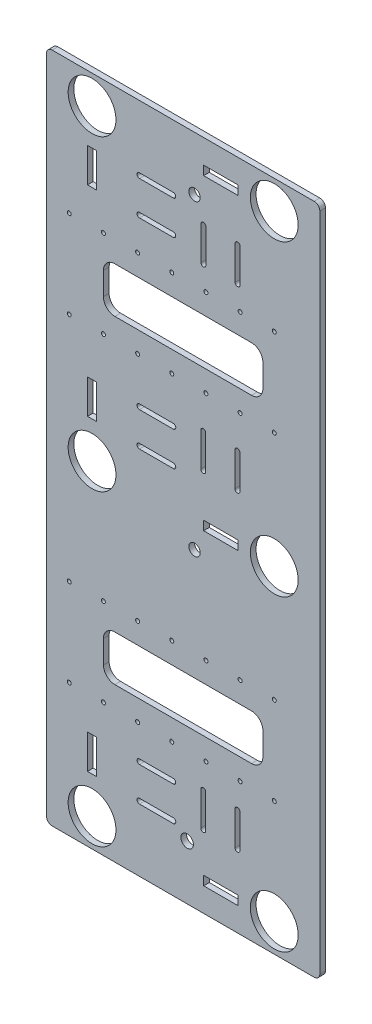
from build123d import *

# Parameters (mm, degrees)
SKETCH_1_W      = 240
SKETCH_1_H      = 590
SKETCH_1_R      = 21
SKETCH_1_R_2    = 1.75
SKETCH_1_R_3    = 5
SKETCH_1_R_4    = 5.5
SKETCH_1_W_2    = 8
SKETCH_1_H_2    = 30
SKETCH_1_W_3    = 30
SKETCH_1_H_3    = 8
EXTRUDE_1_DEPTH = 5
FILLET_1_R      = 5


with BuildPart() as part:
    # 草图1 → 凸台-拉伸1 (new body)
    with BuildSketch(Plane.XY):
        with Locations((-9.883514394, 97.5)):
            Rectangle(SKETCH_1_W, SKETCH_1_H)
        with Locations((70.116485606, 367.5)):
            Circle(SKETCH_1_R, mode=Mode.SUBTRACT)
        with Locations((70.116485606, 97.5)):
            Circle(SKETCH_1_R, mode=Mode.SUBTRACT)
        with Locations((70.116485606, -172.5)):
            Circle(SKETCH_1_R, mode=Mode.SUBTRACT)
        with Locations((-89.883514394, 367.5)):
            Circle(SKETCH_1_R, mode=Mode.SUBTRACT)
        with Locations((-89.883514394, 97.5)):
            Circle(SKETCH_1_R, mode=Mode.SUBTRACT)
        with Locations((-89.883514394, -172.5)):
            Circle(SKETCH_1_R, mode=Mode.SUBTRACT)
        with Locations((-109.883514394, 275.954136104)):
            Circle(SKETCH_1_R_2, mode=Mode.SUBTRACT)
        with Locations((-79.883514394, 275.954136104)):
            Circle(SKETCH_1_R_2, mode=Mode.SUBTRACT)
        with Locations((-49.883514394, 275.954136104)):
            Circle(SKETCH_1_R_2, mode=Mode.SUBTRACT)
        with Locations((-19.883514394, 275.954136104)):
            Circle(SKETCH_1_R_2, mode=Mode.SUBTRACT)
        with Locations((10.116485606, 275.954136104)):
            Circle(SKETCH_1_R_2, mode=Mode.SUBTRACT)
        with Locations((40.116485606, 275.954136104)):
            Circle(SKETCH_1_R_2, mode=Mode.SUBTRACT)
        with Locations((40.116485606, 199.045863896)):
            Circle(SKETCH_1_R_2, mode=Mode.SUBTRACT)
        with Locations((10.116485606, 199.045863896)):
            Circle(SKETCH_1_R_2, mode=Mode.SUBTRACT)
        with Locations((-19.883514394, 199.045863896)):
            Circle(SKETCH_1_R_2, mode=Mode.SUBTRACT)
        with Locations((-49.883514394, 199.045863896)):
            Circle(SKETCH_1_R_2, mode=Mode.SUBTRACT)
        with Locations((-109.883514394, 199.045863896)):
            Circle(SKETCH_1_R_2, mode=Mode.SUBTRACT)
        with Locations((-79.883514394, 199.045863896)):
            Circle(SKETCH_1_R_2, mode=Mode.SUBTRACT)
        with Locations((70.116485606, 275.954136104)):
            Circle(SKETCH_1_R_2, mode=Mode.SUBTRACT)
        with Locations((70.116485606, 199.045863896)):
            Circle(SKETCH_1_R_2, mode=Mode.SUBTRACT)
        with Locations((40.116485606, -80.954136104)):
            Circle(SKETCH_1_R_2, mode=Mode.SUBTRACT)
        with Locations((10.116485606, -80.954136104)):
            Circle(SKETCH_1_R_2, mode=Mode.SUBTRACT)
        with Locations((-19.883514394, -80.954136104)):
            Circle(SKETCH_1_R_2, mode=Mode.SUBTRACT)
        with Locations((-49.883514394, -80.954136104)):
            Circle(SKETCH_1_R_2, mode=Mode.SUBTRACT)
        with Locations((-79.883514394, -80.954136104)):
            Circle(SKETCH_1_R_2, mode=Mode.SUBTRACT)
        with Locations((-109.883514394, -80.954136104)):
            Circle(SKETCH_1_R_2, mode=Mode.SUBTRACT)
        with Locations((70.116485606, -4.045863896)):
            Circle(SKETCH_1_R_2, mode=Mode.SUBTRACT)
        with Locations((-79.883514394, -4.045863896)):
            Circle(SKETCH_1_R_2, mode=Mode.SUBTRACT)
        with Locations((-109.883514394, -4.045863896)):
            Circle(SKETCH_1_R_2, mode=Mode.SUBTRACT)
        with Locations((-49.883514394, -4.045863896)):
            Circle(SKETCH_1_R_2, mode=Mode.SUBTRACT)
        with Locations((-19.883514394, -4.045863896)):
            Circle(SKETCH_1_R_2, mode=Mode.SUBTRACT)
        with Locations((10.116485606, -4.045863896)):
            Circle(SKETCH_1_R_2, mode=Mode.SUBTRACT)
        with Locations((40.116485606, -4.045863896)):
            Circle(SKETCH_1_R_2, mode=Mode.SUBTRACT)
        with Locations((70.116485606, -80.954136104)):
            Circle(SKETCH_1_R_2, mode=Mode.SUBTRACT)
        with Locations((0.12170833, 345.137685343)):
            Circle(SKETCH_1_R_3, mode=Mode.SUBTRACT)
        with Locations((0.12170833, 75.137685343)):
            Circle(SKETCH_1_R_3, mode=Mode.SUBTRACT)
        with Locations((-6.399865329, -149.662314657)):
            Circle(SKETCH_1_R_4, mode=Mode.SUBTRACT)
        with BuildLine():
            Line((-48.233514394, 337.471968803), (-18.533514394, 337.471968803))
            ThreePointArc((-18.533514394, 337.471968803), (-16.391378464, 335.329832872), (-18.533514394, 333.187696941))
            Line((-18.533514394, 333.187696941), (-48.233514394, 333.187696941))
            ThreePointArc((-48.233514394, 333.187696941), (-50.375650325, 335.329832872), (-48.233514394, 337.471968803))
        make_face(mode=Mode.SUBTRACT)
        with BuildLine():
            Line((-48.233514394, 307.455426815), (-18.533514394, 307.455426815))
            ThreePointArc((-18.533514394, 307.455426815), (-16.407920452, 305.329832872), (-18.533514394, 303.20423893))
            Line((-18.533514394, 303.20423893), (-48.233514394, 303.20423893))
            ThreePointArc((-48.233514394, 303.20423893), (-50.359108337, 305.329832872), (-48.233514394, 307.455426815))
        make_face(mode=Mode.SUBTRACT)
        with BuildLine():
            Line((10.016314713, 325.85), (10.016314713, 296.15))
            ThreePointArc((10.016314713, 296.15), (7.887416749, 294.021102036), (5.758518785, 296.15))
            Line((5.758518785, 296.15), (5.758518785, 325.85))
            ThreePointArc((5.758518785, 325.85), (7.887416749, 327.978897964), (10.016314713, 325.85))
        make_face(mode=Mode.SUBTRACT)
        with BuildLine():
            Line((40.045683981, 325.85), (40.045683981, 296.15))
            ThreePointArc((40.045683981, 296.15), (37.887416749, 293.991732767), (35.729149516, 296.15))
            Line((35.729149516, 296.15), (35.729149516, 325.85))
            ThreePointArc((35.729149516, 325.85), (37.887416749, 328.008267233), (40.045683981, 325.85))
        make_face(mode=Mode.SUBTRACT)
        with BuildLine():
            Line((-48.233514394, 161.804708914), (-18.533514394, 161.804708914))
            ThreePointArc((-18.533514394, 161.804708914), (-16.345684038, 159.616878557), (-18.533514394, 157.429048201))
            Line((-18.533514394, 157.429048201), (-48.233514394, 157.429048201))
            ThreePointArc((-48.233514394, 157.429048201), (-50.421344751, 159.616878557), (-48.233514394, 161.804708914))
        make_face(mode=Mode.SUBTRACT)
        with BuildLine():
            Line((-48.233514394, 131.781482951), (-18.533514394, 131.781482951))
            ThreePointArc((-18.533514394, 131.781482951), (-16.368910001, 129.616878557), (-18.533514394, 127.452274164))
            Line((-18.533514394, 127.452274164), (-48.233514394, 127.452274164))
            ThreePointArc((-48.233514394, 127.452274164), (-50.398118788, 129.616878557), (-48.233514394, 131.781482951))
        make_face(mode=Mode.SUBTRACT)
        with BuildLine():
            Line((9.950676084, 168.85), (9.950676084, 139.15))
            ThreePointArc((9.950676084, 139.15), (7.780411189, 136.979735105), (5.610146295, 139.15))
            Line((5.610146295, 139.15), (5.610146295, 168.85))
            ThreePointArc((5.610146295, 168.85), (7.780411189, 171.020264895), (9.950676084, 168.85))
        make_face(mode=Mode.SUBTRACT)
        with BuildLine():
            Line((39.949177668, 168.85), (39.949177668, 139.15))
            ThreePointArc((39.949177668, 139.15), (37.780411189, 136.981233521), (35.611644711, 139.15))
            Line((35.611644711, 139.15), (35.611644711, 168.85))
            ThreePointArc((35.611644711, 168.85), (37.780411189, 171.018766479), (39.949177668, 168.85))
        make_face(mode=Mode.SUBTRACT)
        with BuildLine():
            Line((5.630411189, -104.15), (5.630411189, -133.85))
            ThreePointArc((5.630411189, -133.85), (7.780411189, -136), (9.930411189, -133.85))
            Line((9.930411189, -133.85), (9.930411189, -104.15))
            ThreePointArc((9.930411189, -104.15), (7.780411189, -102), (5.630411189, -104.15))
        make_face(mode=Mode.SUBTRACT)
        with BuildLine():
            Line((35.630411189, -104.15), (35.630411189, -133.85))
            ThreePointArc((35.630411189, -133.85), (37.780411189, -136), (39.930411189, -133.85))
            Line((39.930411189, -133.85), (39.930411189, -104.15))
            ThreePointArc((39.930411189, -104.15), (37.780411189, -102), (35.630411189, -104.15))
        make_face(mode=Mode.SUBTRACT)
        with BuildLine():
            Line((-48.233514394, -108.162604787), (-18.533514394, -108.162604787))
            ThreePointArc((-18.533514394, -108.162604787), (-16.412712465, -110.283406716), (-18.533514394, -112.404208645))
            Line((-18.533514394, -112.404208645), (-48.233514394, -112.404208645))
            ThreePointArc((-48.233514394, -112.404208645), (-50.354316324, -110.283406716), (-48.233514394, -108.162604787))
        make_face(mode=Mode.SUBTRACT)
        with BuildLine():
            Line((-48.233514394, -138.079324724), (-18.533514394, -138.079324724))
            ThreePointArc((-18.533514394, -138.079324724), (-16.329432402, -140.283406716), (-18.533514394, -142.487488708))
            Line((-18.533514394, -142.487488708), (-48.233514394, -142.487488708))
            ThreePointArc((-48.233514394, -142.487488708), (-50.437596387, -140.283406716), (-48.233514394, -138.079324724))
        make_face(mode=Mode.SUBTRACT)
        with Locations((-89.883514394, 144.5)):
            Rectangle(SKETCH_1_W_2, SKETCH_1_H_2, mode=Mode.SUBTRACT)
        with Locations((23.116485606, 97.5)):
            Rectangle(SKETCH_1_W_3, SKETCH_1_H_3, mode=Mode.SUBTRACT)
        with Locations((-89.883514394, 320.5)):
            Rectangle(SKETCH_1_W_2, SKETCH_1_H_2, mode=Mode.SUBTRACT)
        with Locations((-89.883514394, -125.5)):
            Rectangle(SKETCH_1_W_2, SKETCH_1_H_2, mode=Mode.SUBTRACT)
        with Locations((23.116485606, -172.5)):
            Rectangle(SKETCH_1_W_3, SKETCH_1_H_3, mode=Mode.SUBTRACT)
        with Locations((23.116485606, 367.5)):
            Rectangle(SKETCH_1_W_3, SKETCH_1_H_3, mode=Mode.SUBTRACT)
        with BuildLine():
            Line((60.116485606, -32.5), (60.116485606, -52.5))
            ThreePointArc((60.116485606, -52.5), (57.187553417, -59.571067812), (50.116485606, -62.5))
            Line((50.116485606, -62.5), (-69.883514394, -62.5))
            ThreePointArc((-69.883514394, -62.5), (-76.954582206, -59.571067812), (-79.883514394, -52.5))
            Line((-79.883514394, -52.5), (-79.883514394, -32.5))
            ThreePointArc((-79.883514394, -32.5), (-76.954582206, -25.428932188), (-69.883514394, -22.5))
            Line((-69.883514394, -22.5), (50.116485606, -22.5))
            ThreePointArc((50.116485606, -22.5), (57.187553417, -25.428932188), (60.116485606, -32.5))
        make_face(mode=Mode.SUBTRACT)
        with BuildLine():
            Line((50.116485606, 217.5), (-69.883514394, 217.5))
            ThreePointArc((-69.883514394, 217.5), (-76.954582206, 220.428932188), (-79.883514394, 227.5))
            Line((-79.883514394, 227.5), (-79.883514394, 247.5))
            ThreePointArc((-79.883514394, 247.5), (-76.954582206, 254.571067812), (-69.883514394, 257.5))
            Line((-69.883514394, 257.5), (50.116485606, 257.5))
            ThreePointArc((50.116485606, 257.5), (57.187553417, 254.571067812), (60.116485606, 247.5))
            Line((60.116485606, 247.5), (60.116485606, 227.5))
            ThreePointArc((60.116485606, 227.5), (57.187553417, 220.428932188), (50.116485606, 217.5))
        make_face(mode=Mode.SUBTRACT)
    extrude(amount=EXTRUDE_1_DEPTH)

    # 圆角1
    fillet_1_edges = [part.edges().sort_by_distance(p)[0] for p in [
        (-129.883514394, 392.5, 2.5),
        (110.116485606, 392.5, 2.5),
        (110.116485606, -197.5, 2.5),
        (-129.883514394, -197.5, 2.5),
    ]]
    fillet(fillet_1_edges, radius=FILLET_1_R)


solid = part.part
